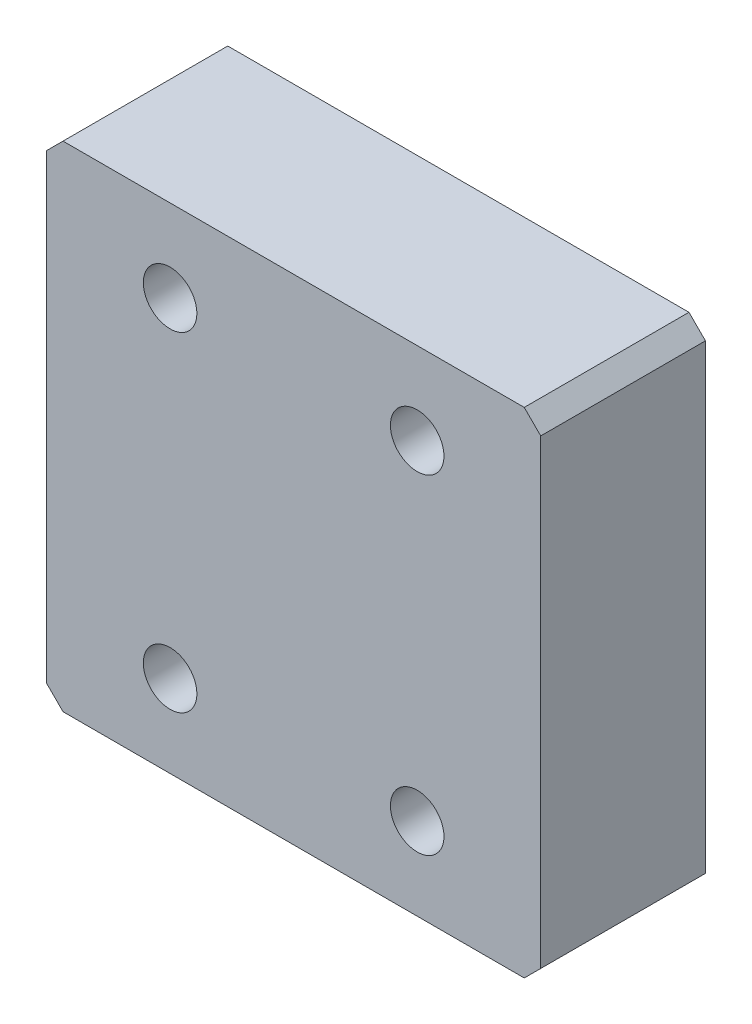
from build123d import *

# Parameters (mm, degrees)
SKETCH1_W           = 60
SKETCH1_H           = 60
SKETCH1_R           = 3.25
BOSS_EXTRUDE1_DEPTH = 20
CHAMFER1_SIZE       = 2


with BuildPart() as part:
    # Sketch1 → Boss-Extrude1 (new body)
    with BuildSketch(Plane.XY):
        Rectangle(SKETCH1_W, SKETCH1_H)
        with Locations((-15, 20)):
            Circle(SKETCH1_R, mode=Mode.SUBTRACT)
        with Locations((15, 20)):
            Circle(SKETCH1_R, mode=Mode.SUBTRACT)
        with Locations((15, -20)):
            Circle(SKETCH1_R, mode=Mode.SUBTRACT)
        with Locations((-15, -20)):
            Circle(SKETCH1_R, mode=Mode.SUBTRACT)
    extrude(amount=BOSS_EXTRUDE1_DEPTH)

    # Chamfer1
    chamfer1_edges = [part.edges().sort_by_distance(p)[0] for p in [
        (30, -30, 10),
        (-30, -30, 10),
        (-30, 30, 10),
        (30, 30, 10),
    ]]
    chamfer(chamfer1_edges, length=CHAMFER1_SIZE)


solid = part.part
